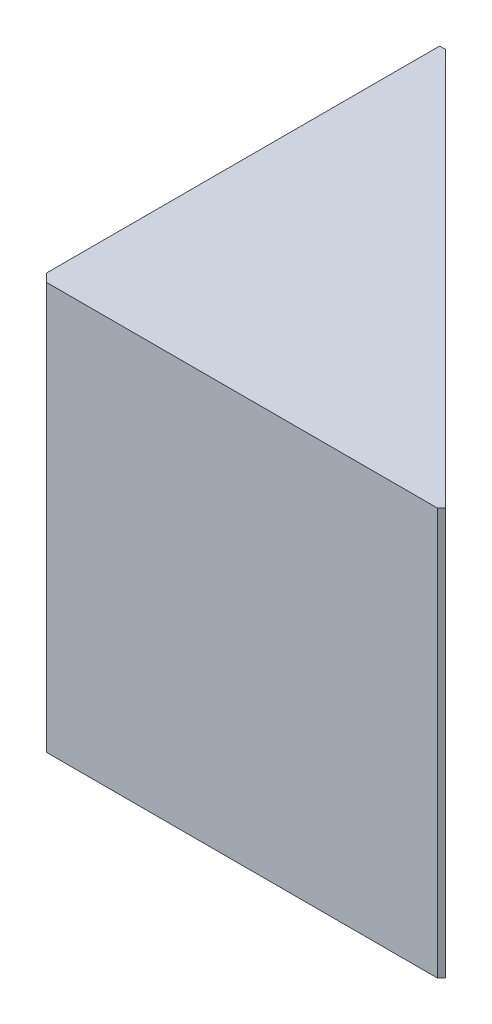
from build123d import *

# Parameters (mm, degrees)
SKETCH_1_W             = 5
SKETCH_1_H             = 5
EXTRUDE_1_DEPTH        = 5
CUT_EXTRUDE_1_DEPTH    = 5
CHAMFER_1_SIZE2        = 0.070710678
CHAMFER_1_SIZE         = 0.1
CHAMFER_1_EDGE_2_SIZE  = 0.1
CHAMFER_1_EDGE_3_SIZE2 = 0.1
CHAMFER_1_EDGE_3_SIZE  = 0.070710678


with BuildPart() as part:
    # 草图1 → 凸台-拉伸1 (new body)
    with BuildSketch(Plane(origin=(0, 0, 0), x_dir=(1, 0, 0), z_dir=(0, 1, 0))):
        Rectangle(SKETCH_1_W, SKETCH_1_H)
    extrude(amount=EXTRUDE_1_DEPTH)

    # 草图2 → 切除-拉伸1 (cut)
    with BuildSketch(Plane(origin=(0, 5, 0), x_dir=(1, 0, 0), z_dir=(0, 1, 0))):
        Polygon((-2.5, 2.5), (2.5, -2.5), (2.5, 2.5), align=None)
    extrude(amount=-CUT_EXTRUDE_1_DEPTH, mode=Mode.SUBTRACT)

    # 倒角1
    chamfer_1_edges = [part.edges().sort_by_distance(p)[0] for p in [
        (2.5, 2.5, 2.5),
    ]]
    chamfer(chamfer_1_edges, length=CHAMFER_1_SIZE, length2=CHAMFER_1_SIZE2)

    # 倒角1 edge 2
    chamfer_1_edge_2_edges = [part.edges().sort_by_distance(p)[0] for p in [
        (-2.5, 2.5, 2.5),
    ]]
    chamfer(chamfer_1_edge_2_edges, length=CHAMFER_1_EDGE_2_SIZE)

    # 倒角1 edge 3
    chamfer_1_edge_3_edges = [part.edges().sort_by_distance(p)[0] for p in [
        (-2.5, 2.5, -2.5),
    ]]
    chamfer(chamfer_1_edge_3_edges, length=CHAMFER_1_EDGE_3_SIZE, length2=CHAMFER_1_EDGE_3_SIZE2)


solid = part.part
